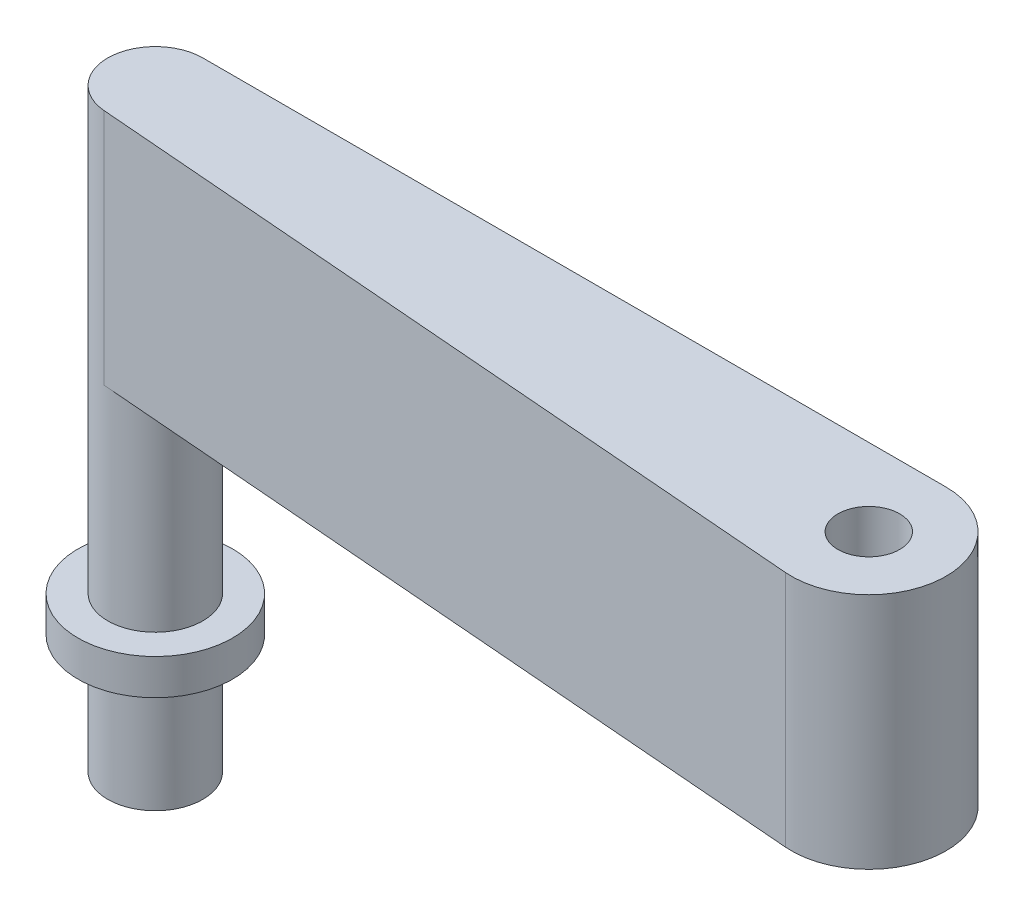
from build123d import *
from build123d.topology import SkipClean

# Parameters (mm, degrees)
SALIENTE_EXTRUIR1_DEPTH = 10
CROQUIS2_R              = 2.6
CORTAR_EXTRUIR1_DEPTH   = 70.745967625
CROQUIS3_R              = 4
SALIENTE_EXTRUIR2_DEPTH = 30
CROQUIS4_R              = 2.6
CORTAR_EXTRUIR2_DEPTH   = 10
SALIENTE_EXTRUIR3_START = -13
CROQUIS5_R              = 6.5
CROQUIS5_R_2            = 4
SALIENTE_EXTRUIR3_DEPTH = 3


with BuildPart() as part:
    # Croquis1 → Saliente-Extruir1 (new, symmetric)
    with BuildSketch(Plane(origin=(0, 0, 0), x_dir=(1, 0, 0), z_dir=(0, 1, 0))):
        with BuildLine():
            Line((-62.5, 6.5), (0, 6.5))
            ThreePointArc((0, 6.5), (6.494806232, -0.259792249), (-0.519169329, -6.479233227))
            Line((-0.519169329, -6.479233227), (-62.819488818, -1.487220447))
            ThreePointArc((-62.819488818, -1.487220447), (-66.496803835, 2.659872153), (-62.5, 6.5))
        make_face()
    extrude(amount=SALIENTE_EXTRUIR1_DEPTH, both=True)

    # Croquis2 → Cortar-Extruir1 (cut, through all)
    with BuildSketch(Plane(origin=(0, 10, 0), x_dir=(1, 0, 0), z_dir=(0, 1, 0))):
        Circle(CROQUIS2_R)
    extrude(amount=-CORTAR_EXTRUIR1_DEPTH, mode=Mode.SUBTRACT)

    # Croquis3 → Saliente-Extruir2 (add)
    with SkipClean():  # the faces are left unmerged after this step: merging them gives an invalid solid
        with BuildSketch(Plane(origin=(0, -10, 0), x_dir=(1, 0, 0), z_dir=(0, 1, 0))):
            with Locations((-62.5, 2.5)):
                Circle(CROQUIS3_R)
        extrude(amount=-SALIENTE_EXTRUIR2_DEPTH)

    # Croquis4 → Cortar-Extruir2 (cut)
    with SkipClean():  # the faces are left unmerged after this step: merging them gives an invalid solid
        with BuildSketch(Plane(origin=(0, -40, 0), x_dir=(-1, 0, 0), z_dir=(0, -1, 0))):
            with Locations((62.5, 2.5)):
                Circle(CROQUIS4_R)
        extrude(amount=-CORTAR_EXTRUIR2_DEPTH, mode=Mode.SUBTRACT)

    # Croquis5 → Saliente-Extruir3 (add)
    with SkipClean():  # the faces are left unmerged after this step: merging them gives an invalid solid
        with BuildSketch(Plane.XZ.offset(40).offset(SALIENTE_EXTRUIR3_START)):
            with Locations((-62.5, -2.5)):
                Circle(CROQUIS5_R)
            with Locations((-62.5, -2.5)):
                Circle(CROQUIS5_R_2, mode=Mode.SUBTRACT)
        extrude(amount=SALIENTE_EXTRUIR3_DEPTH)


solid = part.part
